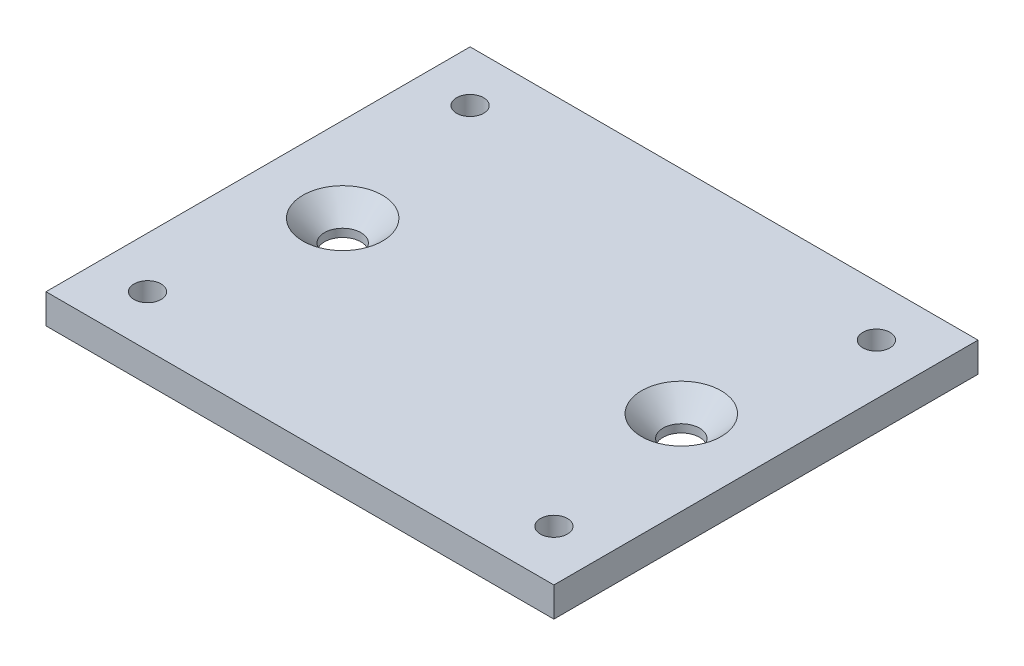
from build123d import *

# Parameters (mm, degrees)
SKETCH1_W                                      = 60
SKETCH1_H                                      = 50.1
SKETCH1_R                                      = 1.5
SKETCH1_R_2                                    = 0.5
BOSS_EXTRUDE2_DEPTH                            = 3.5
M3_CLEARANCE_HOLE1_D                           = 3.2
M3_CLEARANCE_HOLE1_DEPTH                       = 3.5
CSK_FOR_M4_FLAT_HEAD_MACHINE_SCREW1_AT_2_COUNT = 2
CSK_FOR_M4_FLAT_HEAD_MACHINE_SCREW1_AT_2_PITCH = 40


with BuildPart() as part:
    # Sketch1 → Boss-Extrude2 (new body)
    with BuildSketch(Plane(origin=(0, 0, 0), x_dir=(1, 0, 0), z_dir=(0, 1, 0))):
        Rectangle(SKETCH1_W, SKETCH1_H)
        with Locations((-24, 19.05)):
            Circle(SKETCH1_R, mode=Mode.SUBTRACT)
        with Locations((-24, -19.05)):
            Circle(SKETCH1_R, mode=Mode.SUBTRACT)
        with Locations((24, -19.05)):
            Circle(SKETCH1_R, mode=Mode.SUBTRACT)
        with Locations((24, 19.05)):
            Circle(SKETCH1_R, mode=Mode.SUBTRACT)
        with Locations((20, 0)):
            Circle(SKETCH1_R_2, mode=Mode.SUBTRACT)
        with Locations((-20, 0)):
            Circle(SKETCH1_R_2, mode=Mode.SUBTRACT)
    extrude(amount=BOSS_EXTRUDE2_DEPTH)

    # M3 Clearance Hole1
    with Locations(Plane(origin=(0, 3.5, 0), x_dir=(1, 0, 0), z_dir=(0, 1, 0))):
        with Locations((-24, 19.05), (24, 19.05), (24, -19.05), (-24, -19.05)):
            Hole(M3_CLEARANCE_HOLE1_D / 2, depth=M3_CLEARANCE_HOLE1_DEPTH)

    # Sketch5 → CSK for M4 Flat Head Machine Screw1 (revolve, cut)
    with BuildSketch(Plane(origin=(-20, 3.5, 0), x_dir=(0, 0, 1), z_dir=(1, 0, 0))):
        Polygon((0, 0), (0, 3.5), (2.15, 3.5), (2.15, 2.55), (4.7, 0), align=None)
    csk_for_m4_flat_head_machine_screw1 = revolve(axis=Axis((-20, 9.85, 0), (0, -1, 0)), mode=Mode.SUBTRACT)

    # CSK for M4 Flat Head Machine Screw1 at 2: CSK for M4 Flat Head Machine Screw1 ×2
    with Locations(*[(i * CSK_FOR_M4_FLAT_HEAD_MACHINE_SCREW1_AT_2_PITCH, 0, 0) for i in range(1, CSK_FOR_M4_FLAT_HEAD_MACHINE_SCREW1_AT_2_COUNT)]):
        add(csk_for_m4_flat_head_machine_screw1, mode=Mode.SUBTRACT)


solid = part.part
